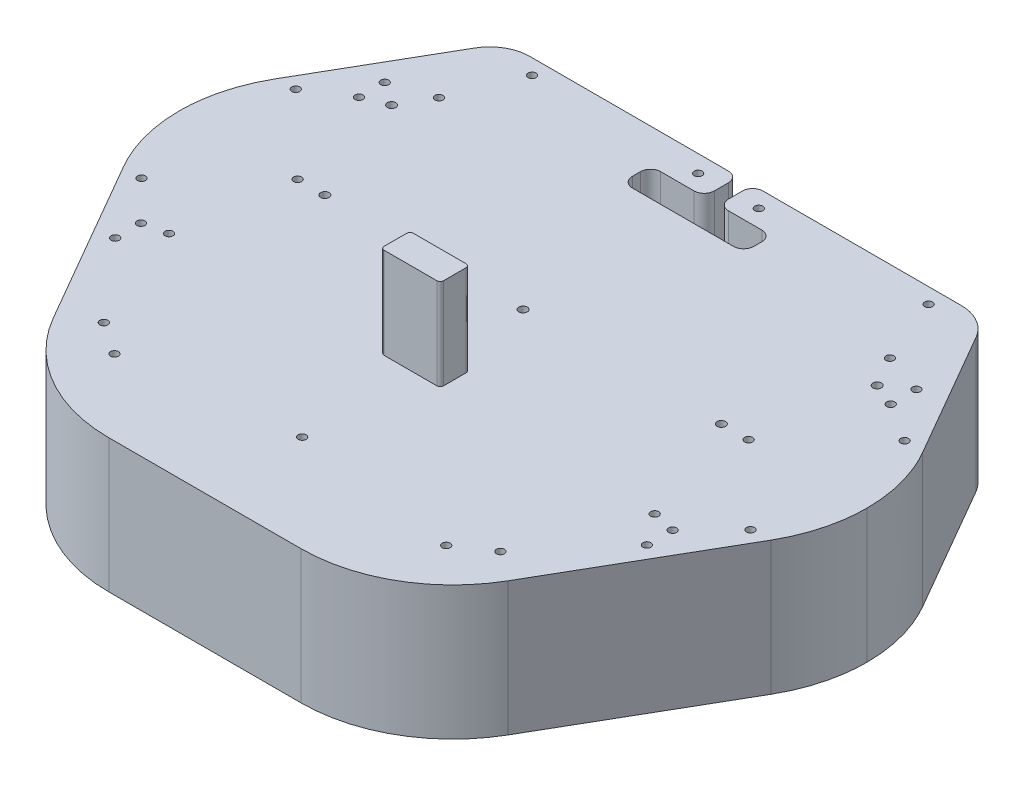
from build123d import *

# Parameters (mm, degrees)
BOSS_EXTRUDE1_DEPTH        = 66
CUT_EXTRUDE1_DEPTH         = 67.0000001
M3_5_CLEARANCE_HOLE1_D     = 4.199808185
M3_5_CLEARANCE_HOLE1_DEPTH = 66.000055
M3_5_CLEARANCE_HOLE2_D     = 3.949622561
M3_5_CLEARANCE_HOLE2_DEPTH = 66.000055
FILLET1_R                  = 5.024738629
FILLET2_R                  = 19.924521471
FILLET3_R                  = 74.958538247
BOSS_EXTRUDE2_DEPTH        = 45


with BuildPart() as part:
    # Sketch1 → Boss-Extrude1 (new body)
    with BuildSketch(Plane(origin=(0, 6, 0), x_dir=(1, 0, 0), z_dir=(0, 1, 0))):
        with BuildLine():
            Line((118.094019457, 109.999994984), (-118.094002078, 109.999994984))
            Line((-118.094002078, 109.999994984), (-159.951896595, 37.499994984))
            add(Edge.make_bspline(
                [(-159.951896595, 37.499994984), (-162.089834317, 33.796773054), (-165.842582605, 25.786056062), (-169.244504237, 13.08991169), (-169.999887381, 4.276053128), (-169.999989967, 0)],
                knots=[5.759586536, 5.759586536, 5.759586536, 5.759586536, 5.930628798, 6.11214304, 6.283185303, 6.283185303, 6.283185303, 6.283185303], degree=3))
            add(Edge.make_bspline(
                [(-169.999989967, 0), (-169.999887381, -4.276053128), (-169.244504237, -13.089911689), (-165.842582605, -25.786056062), (-162.089834317, -33.796773054), (-159.951896595, -37.499994984)],
                knots=[4e-09, 4e-09, 4e-09, 4e-09, 0.171042267, 0.352556509, 0.523598771, 0.523598771, 0.523598771, 0.523598771], degree=3))
            Line((-159.951896595, -37.499994984), (-90.801270189, -157.27241336))
            Line((-90.801270189, -157.27241336), (90.801270189, -157.27241336))
            Line((90.801270189, -157.27241336), (159.951905284, -37.5))
            add(Edge.make_bspline(
                [(159.951905284, -37.5), (162.089843006, -33.79677807), (165.842591294, -25.786061079), (169.244512926, -13.089916706), (169.99989607, -4.276058145), (169.999998656, -5.016e-06)],
                knots=[2.617993882, 2.617993882, 2.617993882, 2.617993882, 2.789036145, 2.970550387, 3.141592649, 3.141592649, 3.141592649, 3.141592649], degree=3))
            add(Edge.make_bspline(
                [(169.999998656, -5.016e-06), (169.99989607, 4.276048112), (169.244512926, 13.089906673), (165.842591294, 25.786051046), (162.089843006, 33.796768038), (159.951905284, 37.499989968)],
                knots=[3.141592658, 3.141592658, 3.141592658, 3.141592658, 3.31263492, 3.494149162, 3.665191425, 3.665191425, 3.665191425, 3.665191425], degree=3))
            Line((159.951905284, 37.499989968), (118.094019457, 109.999994984))
        make_face()
    extrude(amount=-BOSS_EXTRUDE1_DEPTH)

    # Sketch2 → Cut-Extrude1 (cut, through all)
    with BuildSketch(Plane.XZ.offset(60)):
        Polygon((3.5, -110), (3.5, -93), (30, -93), (30, -79), (-30, -79), (-30, -93), (-3.5, -93), (-3.5, -110), align=None)
    extrude(amount=-CUT_EXTRUDE1_DEPTH, mode=Mode.SUBTRACT)

    # M3.5 Clearance Hole1
    with Locations(Plane(origin=(0, -60, 0), x_dir=(-1, 0, 0), z_dir=(0, -1, 0))):
        with Locations((0, -0.001547229), (-97.9932, 0.001547229), (97.9932, 0.001547229), (120, 55.001547229), (-120, 55.001547229)):
            Hole(M3_5_CLEARANCE_HOLE1_D / 2, depth=M3_5_CLEARANCE_HOLE1_DEPTH)

    # M3.5 Clearance Hole2
    with Locations(Plane(origin=(0, -60, 0), x_dir=(-1, 0, 0), z_dir=(0, -1, 0))):
        with Locations((98, 102.43824134), (0, -109.21995866), (98, -109.21995866), (-98, -109.21995866), (111.4552, 69.84995866), (111.4552, -4.134e-05), (-111.4552, 69.84995866), (-111.4552, -4.134e-05), (-120, -55.00004134), (120, -55.00004134), (131.4, 50.30004134), (-131.4, 50.30004134), (131.4, -70.19995866), (-131.4, -70.19995866), (131.4, 63.00004134), (-131.4, 63.00004134), (131.4, -57.49995866), (-131.4, -57.49995866), (15, 101.50004134), (-98, 102.43824134), (-15, 101.50004134), (150.47, 38.10004134), (150.47, -38.09995866), (-150.47, 38.10004134), (-150.47, -38.09995866), (-82, -119.99995866), (82, -119.99995866)):
            Hole(M3_5_CLEARANCE_HOLE2_D / 2, depth=M3_5_CLEARANCE_HOLE2_DEPTH)

    # Fillet1
    fillet1_edges = [part.edges().sort_by_distance(p)[0] for p in [
        (-3.5, -27, -109.999994984),
        (-30, -27, -79),
        (30, -27, -79),
        (3.5, -27, -109.999994984),
        (-30, -27, -93),
        (-3.5, -27, -93),
        (30, -27, -93),
        (3.5, -27, -93),
    ]]
    fillet(fillet1_edges, radius=FILLET1_R)

    # Fillet2
    fillet2_edges = [part.edges().sort_by_distance(p)[0] for p in [
        (118.094019457, -27, -109.999994984),
        (-118.094002078, -27, -109.999994984),
    ]]
    fillet(fillet2_edges, radius=FILLET2_R)

    # Fillet3
    fillet3_edges = [part.edges().sort_by_distance(p)[0] for p in [
        (-90.801270189, -27, 157.27241336),
        (90.801270189, -27, 157.27241336),
    ]]
    fillet(fillet3_edges, radius=FILLET3_R)

    # Sketch7 → Boss-Extrude2 (add)
    with BuildSketch(Plane(origin=(0, 6, 0), x_dir=(1, 0, 0), z_dir=(0, 1, 0))):
        with BuildLine():
            Line((-16.390788815, -41.267338357), (-16.410904507, -52.265499005))
            ThreePointArc((-16.410904507, -52.265499005), (-15.908890548, -53.485611522), (-14.690365147, -53.991465667))
            Line((-14.690365147, -53.991465667), (11.309634853, -53.991465667))
            ThreePointArc((11.309634853, -53.991465667), (12.528160254, -53.485611522), (13.030174213, -52.265499005))
            Line((13.030174213, -52.265499005), (13.010058521, -41.267338357))
            ThreePointArc((13.010058521, -41.267338357), (12.514864968, -40.042764602), (11.309634853, -39.50219277))
            Line((11.309634853, -39.50219277), (-14.690365147, -39.50219277))
            ThreePointArc((-14.690365147, -39.50219277), (-15.915842564, -40.023259701), (-16.390788815, -41.267338357))
        make_face()
    extrude(amount=BOSS_EXTRUDE2_DEPTH)


solid = part.part
